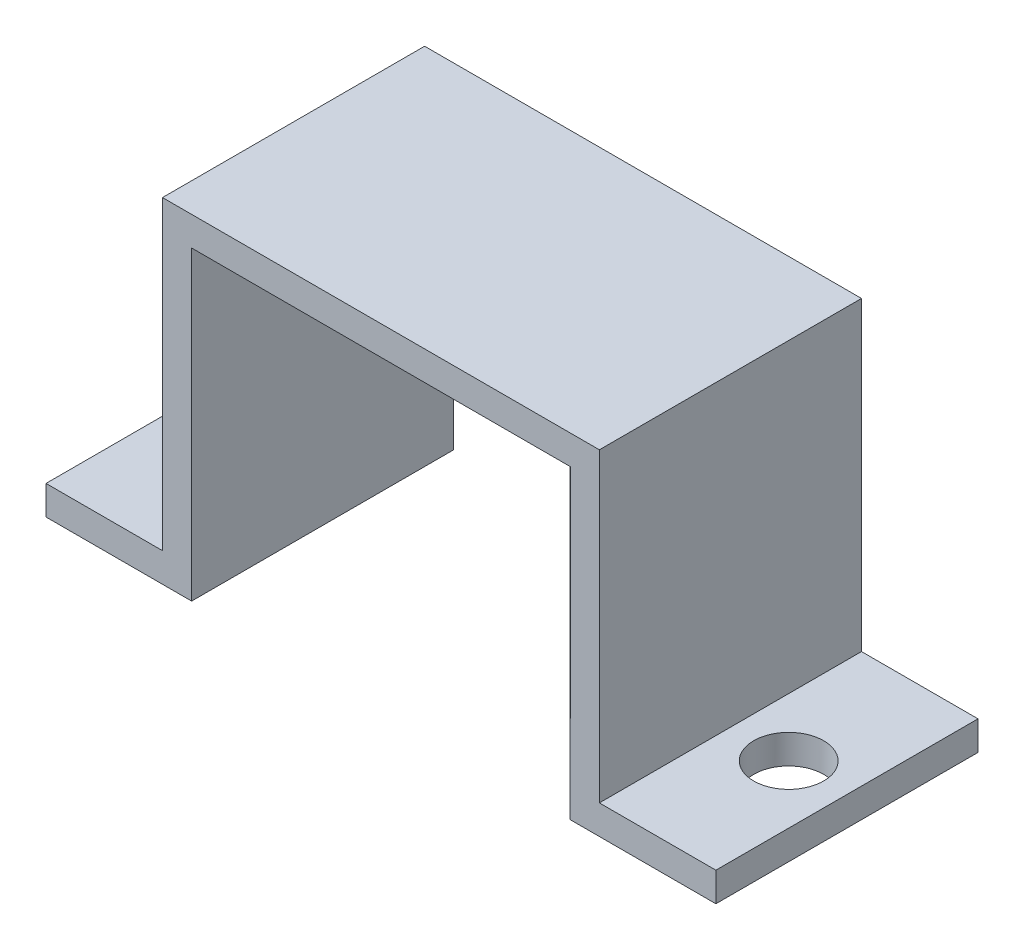
from build123d import *

# Parameters (mm, degrees)
BOSS_EXTRUDE1_DEPTH = 9
SKETCH2_R           = 1.2
CUT_EXTRUDE1_DEPTH  = 29


with BuildPart() as part:
    # Sketch1 → Boss-Extrude1 (new body)
    with BuildSketch(Plane.XY):
        Polygon((7.5, 1), (7.5, 11.5), (-7.5, 11.5), (-7.5, 1), (-11.5, 1), (-11.5, 0), (-6.5, 0), (-6.5, 10.5), (6.5, 10.5), (6.5, 0), (11.5, 0), (11.5, 1), align=None)
    extrude(amount=BOSS_EXTRUDE1_DEPTH)

    # Sketch2 → Cut-Extrude1 (cut)
    with BuildSketch(Plane(origin=(0, 1, 0), x_dir=(1, 0, 0), z_dir=(0, 1, 0))):
        with Locations((9.5, -4.5)):
            Circle(SKETCH2_R)
    cut_extrude1 = extrude(amount=-CUT_EXTRUDE1_DEPTH, mode=Mode.SUBTRACT)

    # Mirror1: Cut-Extrude1 across plane
    add(cut_extrude1.mirror(Plane(origin=(0, 0, 0), x_dir=(0, 0, 1), z_dir=(1, 0, 0))), mode=Mode.SUBTRACT)


solid = part.part
